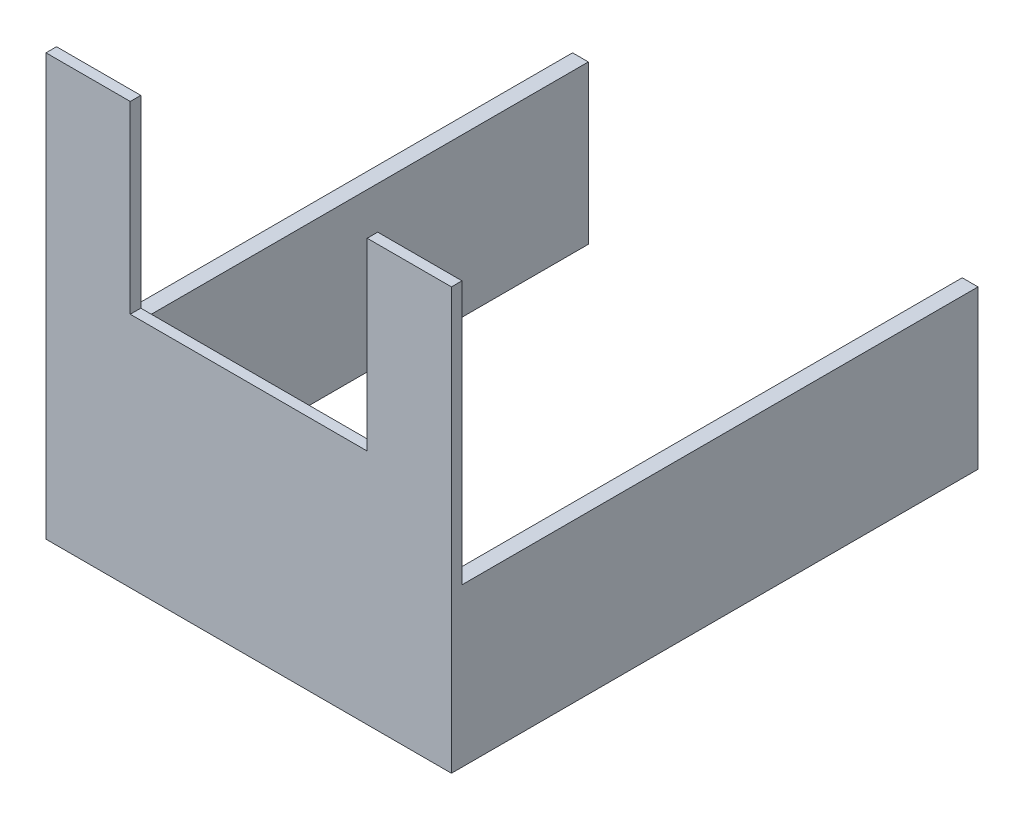
from build123d import *

# Parameters (mm, degrees)
SKETCH_1_W          = 77
SKETCH_1_H          = 80
EXTRUDE_1_DEPTH     = 100
SKETCH_2_W          = 45
SKETCH_2_H          = 35
CUT_EXTRUDE_1_DEPTH = 100
SKETCH_3_W          = 71
SKETCH_3_H          = 80
CUT_EXTRUDE_2_DEPTH = 98
SKETCH_5_W          = 98
SKETCH_5_H          = 50
CUT_EXTRUDE_3_DEPTH = 98


with BuildPart() as part:
    # 草图1 → 凸台-拉伸1 (new body)
    with BuildSketch(Plane.XY):
        with Locations((15.665517241, -23.272413793)):
            Rectangle(SKETCH_1_W, SKETCH_1_H)
    extrude(amount=EXTRUDE_1_DEPTH)

    # 草图2 → 切除-拉伸1 (cut)
    with BuildSketch(Plane.XY.offset(100)):
        with Locations((15.665517241, -0.772413793)):
            Rectangle(SKETCH_2_W, SKETCH_2_H)
    extrude(amount=-CUT_EXTRUDE_1_DEPTH, mode=Mode.SUBTRACT)

    # 草图3 → 切除-拉伸2 (cut)
    with BuildSketch(Plane(origin=(0, 0, 0), x_dir=(-1, 0, 0), z_dir=(0, 0, -1))):
        with Locations((-15.665517241, -23.272413793)):
            Rectangle(SKETCH_3_W, SKETCH_3_H)
    extrude(amount=-CUT_EXTRUDE_2_DEPTH, mode=Mode.SUBTRACT)

    # 草图5 → 切除-拉伸3 (cut)
    with BuildSketch(Plane.ZY.offset(22.834482759)):
        with Locations((49, -8.272413793)):
            Rectangle(SKETCH_5_W, SKETCH_5_H)
    extrude(amount=-CUT_EXTRUDE_3_DEPTH, mode=Mode.SUBTRACT)


solid = part.part
